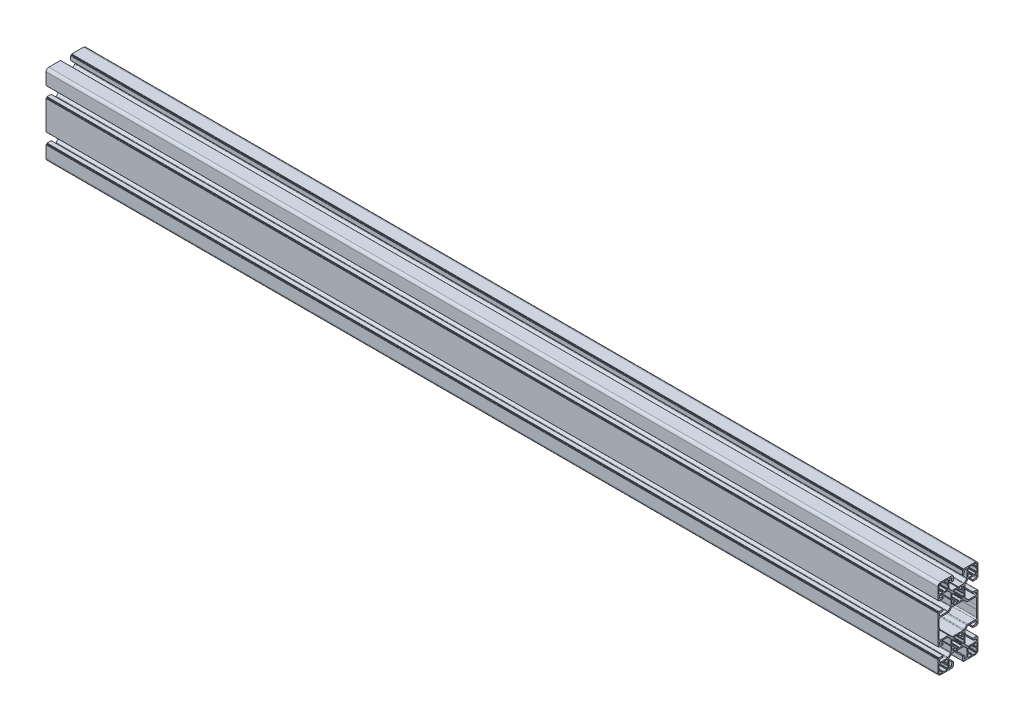
from build123d import *

# Parameters (mm, degrees)
EXTRUDE_1_DEPTH   = 1000
MOVE_BODY_1_ANGLE = 120


with BuildPart() as part:
    # Эскиз1 → Бобышка-Вытянуть1 (new body)
    with BuildSketch(Plane.XY):
        with BuildLine():
            Line((-18.199845697, -23.509977215), (14.150154303, -23.509977215))
            ThreePointArc((14.150154303, -23.509977215), (14.326930998, -23.43675391), (14.400154303, -23.259977215))
            Line((14.400154303, -23.259977215), (14.400154303, -22.609977215))
            ThreePointArc((14.400154303, -22.609977215), (14.429443625, -22.539266537), (14.500154303, -22.509977215))
            Line((14.500154303, -22.509977215), (15.075154303, -22.509977215))
            ThreePointArc((15.075154303, -22.509977215), (15.251930998, -22.43675391), (15.325154303, -22.259977215))
            Line((15.325154303, -22.259977215), (15.325154303, -17.759977215))
            ThreePointArc((15.325154303, -17.759977215), (15.251930998, -17.58320052), (15.075154303, -17.509977215))
            Line((15.075154303, -17.509977215), (13.979405651, -17.509977215))
            ThreePointArc((13.979405651, -17.509977215), (13.821232671, -17.566376314), (13.734426201, -17.710126745))
            Line((13.734426201, -17.710126745), (13.03048423, -21.169498717))
            ThreePointArc((13.03048423, -21.169498717), (12.752703525, -21.629500097), (12.246549992, -21.809977215))
            Line((12.246549992, -21.809977215), (11.175154303, -21.809977215))
            ThreePointArc((11.175154303, -21.809977215), (10.609468878, -21.57566264), (10.375154303, -21.009977215))
            Line((10.375154303, -21.009977215), (10.375154303, -12.726272305))
            ThreePointArc((10.375154303, -12.726272305), (10.451274771, -12.343588873), (10.668047522, -12.019165524))
            Line((10.668047522, -12.019165524), (13.384342612, -9.302870434))
            ThreePointArc((13.384342612, -9.302870434), (13.708765961, -9.086097682), (14.091449394, -9.009977215))
            Line((14.091449394, -9.009977215), (19.944697958, -9.009977215))
            ThreePointArc((19.944697958, -9.009977215), (20.021285838, -8.997956829), (20.090508791, -8.963051588))
            Line((20.090508791, -8.963051588), (20.41682997, -8.728747466))
            ThreePointArc((20.41682997, -8.728747466), (20.475154303, -8.709977215), (20.533478636, -8.728747466))
            Line((20.533478636, -8.728747466), (20.859799816, -8.963051588))
            ThreePointArc((20.859799816, -8.963051588), (20.929022769, -8.997956829), (21.005610648, -9.009977215))
            Line((21.005610648, -9.009977215), (26.858859213, -9.009977215))
            ThreePointArc((26.858859213, -9.009977215), (27.241542645, -9.086097682), (27.565965994, -9.302870434))
            Line((27.565965994, -9.302870434), (30.282261084, -12.019165524))
            ThreePointArc((30.282261084, -12.019165524), (30.499033836, -12.343588873), (30.575154303, -12.726272305))
            Line((30.575154303, -12.726272305), (30.575154303, -21.009977215))
            ThreePointArc((30.575154303, -21.009977215), (30.340839728, -21.57566264), (29.775154303, -21.809977215))
            Line((29.775154303, -21.809977215), (28.703758615, -21.809977215))
            ThreePointArc((28.703758615, -21.809977215), (28.197605082, -21.629500097), (27.919824376, -21.169498717))
            Line((27.919824376, -21.169498717), (27.215882405, -17.710126746))
            ThreePointArc((27.215882405, -17.710126746), (27.129075935, -17.566376315), (26.970902956, -17.509977215))
            Line((26.970902956, -17.509977215), (25.875154303, -17.509977215))
            ThreePointArc((25.875154303, -17.509977215), (25.698377608, -17.58320052), (25.625154303, -17.759977215))
            Line((25.625154303, -17.759977215), (25.625154303, -22.259977215))
            ThreePointArc((25.625154303, -22.259977215), (25.698377608, -22.43675391), (25.875154303, -22.509977215))
            Line((25.875154303, -22.509977215), (26.450154303, -22.509977215))
            ThreePointArc((26.450154303, -22.509977215), (26.520864981, -22.539266537), (26.550154303, -22.609977215))
            Line((26.550154303, -22.609977215), (26.550154303, -23.259977215))
            ThreePointArc((26.550154303, -23.259977215), (26.623377608, -23.43675391), (26.800154303, -23.509977215))
            Line((26.800154303, -23.509977215), (39.975154303, -23.509977215))
            ThreePointArc((39.975154303, -23.509977215), (42.096474645, -22.631297574), (42.975154303, -20.509977239))
            Line((42.975154303, -20.509977239), (42.975154303, -7.334977239))
            ThreePointArc((42.975154303, -7.334977239), (42.901930998, -7.158200544), (42.725154303, -7.084977239))
            Line((42.725154303, -7.084977239), (42.075154303, -7.084977239))
            ThreePointArc((42.075154303, -7.084977239), (42.004443625, -7.055687917), (41.975154303, -6.984977239))
            Line((41.975154303, -6.984977239), (41.975154303, -6.409977239))
            ThreePointArc((41.975154303, -6.409977239), (41.901930998, -6.233200544), (41.725154303, -6.159977239))
            Line((41.725154303, -6.159977239), (37.225154303, -6.159977239))
            ThreePointArc((37.225154303, -6.159977239), (37.048377608, -6.233200544), (36.975154303, -6.409977239))
            Line((36.975154303, -6.409977239), (36.975154303, -7.505725892))
            ThreePointArc((36.975154303, -7.505725892), (37.031553402, -7.663898871), (37.175303834, -7.750705341))
            Line((37.175303834, -7.750705341), (40.634675805, -8.454647312))
            ThreePointArc((40.634675805, -8.454647312), (41.094677185, -8.732428017), (41.275154303, -9.238581551))
            Line((41.275154303, -9.238581551), (41.275154303, -10.309977239))
            ThreePointArc((41.275154303, -10.309977239), (41.040839728, -10.875662664), (40.475154303, -11.109977239))
            Line((40.475154303, -11.109977239), (32.191449393, -11.109977239))
            ThreePointArc((32.191449393, -11.109977239), (31.808765961, -11.033856771), (31.484342612, -10.81708402))
            Line((31.484342612, -10.81708402), (28.768047522, -8.10078893))
            ThreePointArc((28.768047522, -8.10078893), (28.55127477, -7.776365581), (28.475154303, -7.393682149))
            Line((28.475154303, -7.393682149), (28.475154303, -1.540433584))
            ThreePointArc((28.475154303, -1.540433584), (28.463133917, -1.463845704), (28.428228676, -1.394622751))
            Line((28.428228676, -1.394622751), (28.193924554, -1.068301572))
            ThreePointArc((28.193924554, -1.068301572), (28.175154303, -1.009977239), (28.193924554, -0.951652906))
            Line((28.193924554, -0.951652906), (28.428228676, -0.625331726))
            ThreePointArc((28.428228676, -0.625331726), (28.463133917, -0.556108773), (28.475154303, -0.479520894))
            Line((28.475154303, -0.479520894), (28.475154303, 5.373727671))
            ThreePointArc((28.475154303, 5.373727671), (28.55127477, 5.756411103), (28.768047522, 6.080834452))
            Line((28.768047522, 6.080834452), (31.484342612, 8.797129542))
            ThreePointArc((31.484342612, 8.797129542), (31.808765961, 9.013902294), (32.191449393, 9.090022761))
            Line((32.191449393, 9.090022761), (40.475154303, 9.090022761))
            ThreePointArc((40.475154303, 9.090022761), (41.040839728, 8.855708186), (41.275154303, 8.290022761))
            Line((41.275154303, 8.290022761), (41.275154303, 7.218627073))
            ThreePointArc((41.275154303, 7.218627073), (41.094677185, 6.71247354), (40.634675805, 6.434692834))
            Line((40.634675805, 6.434692834), (37.175303834, 5.730750863))
            ThreePointArc((37.175303834, 5.730750863), (37.031553402, 5.643944393), (36.975154303, 5.485771414))
            Line((36.975154303, 5.485771414), (36.975154303, 4.390022761))
            ThreePointArc((36.975154303, 4.390022761), (37.048377608, 4.213246066), (37.225154303, 4.140022761))
            Line((37.225154303, 4.140022761), (41.725154303, 4.140022761))
            ThreePointArc((41.725154303, 4.140022761), (41.901930998, 4.213246066), (41.975154303, 4.390022761))
            Line((41.975154303, 4.390022761), (41.975154303, 4.965022761))
            ThreePointArc((41.975154303, 4.965022761), (42.004443625, 5.035733439), (42.075154303, 5.065022761))
            Line((42.075154303, 5.065022761), (42.725154303, 5.065022761))
            ThreePointArc((42.725154303, 5.065022761), (42.901930998, 5.138246066), (42.975154303, 5.315022761))
            Line((42.975154303, 5.315022761), (42.975154303, 18.490022809))
            ThreePointArc((42.975154303, 18.490022809), (42.096474637, 20.611343152), (39.975154279, 21.490022785))
            Line((39.975154279, 21.490022785), (26.800154279, 21.490022785))
            ThreePointArc((26.800154279, 21.490022785), (26.623377584, 21.41679948), (26.550154279, 21.240022785))
            Line((26.550154279, 21.240022785), (26.550154279, 20.590022785))
            ThreePointArc((26.550154279, 20.590022785), (26.520864957, 20.519312107), (26.450154279, 20.490022785))
            Line((26.450154279, 20.490022785), (25.875154279, 20.490022785))
            ThreePointArc((25.875154279, 20.490022785), (25.698377584, 20.41679948), (25.625154279, 20.240022785))
            Line((25.625154279, 20.240022785), (25.625154279, 15.740022785))
            ThreePointArc((25.625154279, 15.740022785), (25.698377584, 15.56324609), (25.875154279, 15.490022785))
            Line((25.875154279, 15.490022785), (26.970902932, 15.490022785))
            ThreePointArc((26.970902932, 15.490022785), (27.129075911, 15.546421884), (27.215882381, 15.690172316))
            Line((27.215882381, 15.690172316), (27.919824352, 19.149544287))
            ThreePointArc((27.919824352, 19.149544287), (28.197605058, 19.609545667), (28.703758591, 19.790022785))
            Line((28.703758591, 19.790022785), (29.775154279, 19.790022785))
            ThreePointArc((29.775154279, 19.790022785), (30.340839704, 19.55570821), (30.575154279, 18.990022785))
            Line((30.575154279, 18.990022785), (30.575154279, 10.706317875))
            ThreePointArc((30.575154279, 10.706317875), (30.499033812, 10.323634443), (30.28226106, 9.999211094))
            Line((30.28226106, 9.999211094), (27.56596597, 7.282916004))
            ThreePointArc((27.56596597, 7.282916004), (27.241542621, 7.066143252), (26.858859189, 6.990022785))
            Line((26.858859189, 6.990022785), (21.005610624, 6.990022785))
            ThreePointArc((21.005610624, 6.990022785), (20.929022745, 6.978002399), (20.859799792, 6.943097158))
            Line((20.859799792, 6.943097158), (20.533478612, 6.708793036))
            ThreePointArc((20.533478612, 6.708793036), (20.475154279, 6.690022785), (20.416829946, 6.708793036))
            Line((20.416829946, 6.708793036), (20.090508767, 6.943097158))
            ThreePointArc((20.090508767, 6.943097158), (20.021285814, 6.978002399), (19.944697934, 6.990022785))
            Line((19.944697934, 6.990022785), (14.09144937, 6.990022785))
            ThreePointArc((14.09144937, 6.990022785), (13.708765937, 7.066143252), (13.384342588, 7.282916004))
            Line((13.384342588, 7.282916004), (10.668047498, 9.999211094))
            ThreePointArc((10.668047498, 9.999211094), (10.451274747, 10.323634443), (10.375154279, 10.706317875))
            Line((10.375154279, 10.706317875), (10.375154279, 18.990022785))
            ThreePointArc((10.375154279, 18.990022785), (10.609468854, 19.55570821), (11.175154279, 19.790022785))
            Line((11.175154279, 19.790022785), (12.246549968, 19.790022785))
            ThreePointArc((12.246549968, 19.790022785), (12.752703501, 19.609545666), (13.030484206, 19.149544287))
            Line((13.030484206, 19.149544287), (13.734426177, 15.690172315))
            ThreePointArc((13.734426177, 15.690172315), (13.821232647, 15.546421884), (13.979405627, 15.490022785))
            Line((13.979405627, 15.490022785), (15.075154279, 15.490022785))
            ThreePointArc((15.075154279, 15.490022785), (15.251930974, 15.56324609), (15.325154279, 15.740022785))
            Line((15.325154279, 15.740022785), (15.325154279, 20.240022785))
            ThreePointArc((15.325154279, 20.240022785), (15.251930974, 20.41679948), (15.075154279, 20.490022785))
            Line((15.075154279, 20.490022785), (14.500154279, 20.490022785))
            ThreePointArc((14.500154279, 20.490022785), (14.429443601, 20.519312107), (14.400154279, 20.590022785))
            Line((14.400154279, 20.590022785), (14.400154279, 21.240022785))
            ThreePointArc((14.400154279, 21.240022785), (14.326930975, 21.41679948), (14.150154279, 21.490022785))
            Line((14.150154279, 21.490022785), (-18.199845721, 21.490022785))
            ThreePointArc((-18.199845721, 21.490022785), (-18.376622416, 21.41679948), (-18.449845721, 21.240022785))
            Line((-18.449845721, 21.240022785), (-18.449845721, 20.590022785))
            ThreePointArc((-18.449845721, 20.590022785), (-18.479135043, 20.519312107), (-18.549845721, 20.490022785))
            Line((-18.549845721, 20.490022785), (-19.124845721, 20.490022785))
            ThreePointArc((-19.124845721, 20.490022785), (-19.301622416, 20.41679948), (-19.374845721, 20.240022785))
            Line((-19.374845721, 20.240022785), (-19.374845721, 15.740022785))
            ThreePointArc((-19.374845721, 15.740022785), (-19.301622416, 15.56324609), (-19.124845721, 15.490022785))
            Line((-19.124845721, 15.490022785), (-18.029097068, 15.490022785))
            ThreePointArc((-18.029097068, 15.490022785), (-17.870924089, 15.546421884), (-17.784117619, 15.690172315))
            Line((-17.784117619, 15.690172315), (-17.080175648, 19.149544287))
            ThreePointArc((-17.080175648, 19.149544287), (-16.802394942, 19.609545666), (-16.296241409, 19.790022785))
            Line((-16.296241409, 19.790022785), (-15.224845721, 19.790022785))
            ThreePointArc((-15.224845721, 19.790022785), (-14.659160296, 19.55570821), (-14.424845721, 18.990022785))
            Line((-14.424845721, 18.990022785), (-14.424845721, 10.706317875))
            ThreePointArc((-14.424845721, 10.706317875), (-14.500966188, 10.323634443), (-14.71773894, 9.999211094))
            Line((-14.71773894, 9.999211094), (-17.43403403, 7.282916004))
            ThreePointArc((-17.43403403, 7.282916004), (-17.758457379, 7.066143252), (-18.141140811, 6.990022785))
            Line((-18.141140811, 6.990022785), (-23.994389376, 6.990022785))
            ThreePointArc((-23.994389376, 6.990022785), (-24.070977255, 6.978002399), (-24.140200208, 6.943097158))
            Line((-24.140200208, 6.943097158), (-24.466521388, 6.708793036))
            ThreePointArc((-24.466521388, 6.708793036), (-24.524845721, 6.690022785), (-24.583170054, 6.708793036))
            Line((-24.583170054, 6.708793036), (-24.909491233, 6.943097158))
            ThreePointArc((-24.909491233, 6.943097158), (-24.978714186, 6.978002399), (-25.055302066, 6.990022785))
            Line((-25.055302066, 6.990022785), (-30.90855063, 6.990022785))
            ThreePointArc((-30.90855063, 6.990022785), (-31.291234063, 7.066143252), (-31.615657411, 7.282916004))
            Line((-31.615657411, 7.282916004), (-34.331952502, 9.999211094))
            ThreePointArc((-34.331952502, 9.999211094), (-34.548725253, 10.323634443), (-34.624845721, 10.706317875))
            Line((-34.624845721, 10.706317875), (-34.624845721, 18.990022785))
            ThreePointArc((-34.624845721, 18.990022785), (-34.390531146, 19.55570821), (-33.824845721, 19.790022785))
            Line((-33.824845721, 19.790022785), (-32.753450032, 19.790022785))
            ThreePointArc((-32.753450032, 19.790022785), (-32.247296499, 19.609545667), (-31.969515794, 19.149544287))
            Line((-31.969515794, 19.149544287), (-31.265573823, 15.690172316))
            ThreePointArc((-31.265573823, 15.690172316), (-31.178767352, 15.546421884), (-31.020594373, 15.490022785))
            Line((-31.020594373, 15.490022785), (-29.924845721, 15.490022785))
            ThreePointArc((-29.924845721, 15.490022785), (-29.748069025, 15.56324609), (-29.674845721, 15.740022785))
            Line((-29.674845721, 15.740022785), (-29.674845721, 20.240022785))
            ThreePointArc((-29.674845721, 20.240022785), (-29.748069025, 20.41679948), (-29.924845721, 20.490022785))
            Line((-29.924845721, 20.490022785), (-30.499845721, 20.490022785))
            ThreePointArc((-30.499845721, 20.490022785), (-30.570556399, 20.519312107), (-30.599845721, 20.590022785))
            Line((-30.599845721, 20.590022785), (-30.599845721, 21.240022785))
            ThreePointArc((-30.599845721, 21.240022785), (-30.673069025, 21.41679948), (-30.849845721, 21.490022785))
            Line((-30.849845721, 21.490022785), (-44.024845721, 21.490022785))
            ThreePointArc((-44.024845721, 21.490022785), (-46.146166064, 20.611343128), (-47.024845721, 18.490022785))
            Line((-47.024845721, 18.490022785), (-47.024845721, 5.315022785))
            ThreePointArc((-47.024845721, 5.315022785), (-46.951622416, 5.13824609), (-46.774845721, 5.065022785))
            Line((-46.774845721, 5.065022785), (-46.124845721, 5.065022785))
            ThreePointArc((-46.124845721, 5.065022785), (-46.054135043, 5.035733463), (-46.024845721, 4.965022785))
            Line((-46.024845721, 4.965022785), (-46.024845721, 4.390022785))
            ThreePointArc((-46.024845721, 4.390022785), (-45.951622416, 4.21324609), (-45.774845721, 4.140022785))
            Line((-45.774845721, 4.140022785), (-41.274845721, 4.140022785))
            ThreePointArc((-41.274845721, 4.140022785), (-41.098069025, 4.21324609), (-41.024845721, 4.390022785))
            Line((-41.024845721, 4.390022785), (-41.024845721, 5.485771438))
            ThreePointArc((-41.024845721, 5.485771438), (-41.08124482, 5.643944417), (-41.224995251, 5.730750887))
            Line((-41.224995251, 5.730750887), (-44.684367223, 6.434692858))
            ThreePointArc((-44.684367223, 6.434692858), (-45.144368602, 6.712473563), (-45.324845721, 7.218627097))
            Line((-45.324845721, 7.218627097), (-45.324845721, 8.290022785))
            ThreePointArc((-45.324845721, 8.290022785), (-45.090531146, 8.85570821), (-44.524845721, 9.090022785))
            Line((-44.524845721, 9.090022785), (-36.241140811, 9.090022785))
            ThreePointArc((-36.241140811, 9.090022785), (-35.858457379, 9.013902317), (-35.53403403, 8.797129566))
            Line((-35.53403403, 8.797129566), (-32.817738939, 6.080834476))
            ThreePointArc((-32.817738939, 6.080834476), (-32.600966188, 5.756411127), (-32.524845721, 5.373727695))
            Line((-32.524845721, 5.373727695), (-32.524845721, -0.47952087))
            ThreePointArc((-32.524845721, -0.47952087), (-32.512825317, -0.556108771), (-32.477920046, -0.625331736))
            Line((-32.477920046, -0.625331736), (-32.243615947, -0.951652882))
            ThreePointArc((-32.243615947, -0.951652882), (-32.224845697, -1.009977215), (-32.243615947, -1.068301548))
            Line((-32.243615947, -1.068301548), (-32.47792007, -1.394622728))
            ThreePointArc((-32.47792007, -1.394622728), (-32.512825311, -1.46384568), (-32.524845697, -1.54043356))
            Line((-32.524845697, -1.54043356), (-32.524845697, -7.393682125))
            ThreePointArc((-32.524845697, -7.393682125), (-32.600966164, -7.776365557), (-32.817738916, -8.100788906))
            Line((-32.817738916, -8.100788906), (-35.534034006, -10.817083996))
            ThreePointArc((-35.534034006, -10.817083996), (-35.858457355, -11.033856748), (-36.241140787, -11.109977215))
            Line((-36.241140787, -11.109977215), (-44.524845697, -11.109977215))
            ThreePointArc((-44.524845697, -11.109977215), (-45.090531122, -10.87566264), (-45.324845697, -10.309977215))
            Line((-45.324845697, -10.309977215), (-45.324845697, -9.238581527))
            ThreePointArc((-45.324845697, -9.238581527), (-45.144368578, -8.732427994), (-44.684367199, -8.454647288))
            Line((-44.684367199, -8.454647288), (-41.224995227, -7.750705317))
            ThreePointArc((-41.224995227, -7.750705317), (-41.081244796, -7.663898847), (-41.024845697, -7.505725868))
            Line((-41.024845697, -7.505725868), (-41.024845697, -6.409977215))
            ThreePointArc((-41.024845697, -6.409977215), (-41.098069001, -6.23320052), (-41.274845697, -6.159977215))
            Line((-41.274845697, -6.159977215), (-45.774845697, -6.159977215))
            ThreePointArc((-45.774845697, -6.159977215), (-45.951622392, -6.23320052), (-46.024845697, -6.409977215))
            Line((-46.024845697, -6.409977215), (-46.024845697, -6.984977215))
            ThreePointArc((-46.024845697, -6.984977215), (-46.054135018, -7.055687893), (-46.124845697, -7.084977215))
            Line((-46.124845697, -7.084977215), (-46.774845697, -7.084977215))
            ThreePointArc((-46.774845697, -7.084977215), (-46.951622392, -7.15820052), (-47.024845697, -7.334977215))
            Line((-47.024845697, -7.334977215), (-47.024845697, -20.509977215))
            ThreePointArc((-47.024845697, -20.509977215), (-46.14616604, -22.631297559), (-44.024845697, -23.509977215))
            Line((-44.024845697, -23.509977215), (-30.849845697, -23.509977215))
            ThreePointArc((-30.849845697, -23.509977215), (-30.673069001, -23.43675391), (-30.599845697, -23.259977215))
            Line((-30.599845697, -23.259977215), (-30.599845697, -22.609977215))
            ThreePointArc((-30.599845697, -22.609977215), (-30.570556375, -22.539266537), (-30.499845697, -22.509977215))
            Line((-30.499845697, -22.509977215), (-29.924845697, -22.509977215))
            ThreePointArc((-29.924845697, -22.509977215), (-29.748069001, -22.43675391), (-29.674845697, -22.259977215))
            Line((-29.674845697, -22.259977215), (-29.674845697, -17.759977215))
            ThreePointArc((-29.674845697, -17.759977215), (-29.748069001, -17.58320052), (-29.924845697, -17.509977215))
            Line((-29.924845697, -17.509977215), (-31.020594349, -17.509977215))
            ThreePointArc((-31.020594349, -17.509977215), (-31.178767328, -17.566376315), (-31.265573799, -17.710126746))
            Line((-31.265573799, -17.710126746), (-31.96951577, -21.169498717))
            ThreePointArc((-31.96951577, -21.169498717), (-32.247296475, -21.629500097), (-32.753450008, -21.809977215))
            Line((-32.753450008, -21.809977215), (-33.824845697, -21.809977215))
            ThreePointArc((-33.824845697, -21.809977215), (-34.390531122, -21.57566264), (-34.624845697, -21.009977215))
            Line((-34.624845697, -21.009977215), (-34.624845697, -12.726272305))
            ThreePointArc((-34.624845697, -12.726272305), (-34.548725229, -12.343588873), (-34.331952478, -12.019165524))
            Line((-34.331952478, -12.019165524), (-31.615657387, -9.302870434))
            ThreePointArc((-31.615657387, -9.302870434), (-31.291234039, -9.086097683), (-30.908550606, -9.009977215))
            Line((-30.908550606, -9.009977215), (-25.055302042, -9.009977215))
            ThreePointArc((-25.055302042, -9.009977215), (-24.978714162, -8.997956829), (-24.909491209, -8.963051588))
            Line((-24.909491209, -8.963051588), (-24.58317003, -8.728747466))
            ThreePointArc((-24.58317003, -8.728747466), (-24.524845697, -8.709977215), (-24.466521364, -8.728747466))
            Line((-24.466521364, -8.728747466), (-24.140200184, -8.963051588))
            ThreePointArc((-24.140200184, -8.963051588), (-24.070977231, -8.997956829), (-23.994389352, -9.009977215))
            Line((-23.994389352, -9.009977215), (-18.141140787, -9.009977215))
            ThreePointArc((-18.141140787, -9.009977215), (-17.758457355, -9.086097683), (-17.434034006, -9.302870434))
            Line((-17.434034006, -9.302870434), (-14.717738916, -12.019165524))
            ThreePointArc((-14.717738916, -12.019165524), (-14.500966164, -12.343588873), (-14.424845697, -12.726272305))
            Line((-14.424845697, -12.726272305), (-14.424845697, -21.009977215))
            ThreePointArc((-14.424845697, -21.009977215), (-14.659160272, -21.57566264), (-15.224845697, -21.809977215))
            Line((-15.224845697, -21.809977215), (-16.296241385, -21.809977215))
            ThreePointArc((-16.296241385, -21.809977215), (-16.802394918, -21.629500097), (-17.080175624, -21.169498717))
            Line((-17.080175624, -21.169498717), (-17.784117594, -17.710126746))
            ThreePointArc((-17.784117594, -17.710126746), (-17.870924065, -17.566376314), (-18.029097044, -17.509977215))
            Line((-18.029097044, -17.509977215), (-19.124845697, -17.509977215))
            ThreePointArc((-19.124845697, -17.509977215), (-19.301622392, -17.58320052), (-19.374845697, -17.759977215))
            Line((-19.374845697, -17.759977215), (-19.374845697, -22.259977215))
            ThreePointArc((-19.374845697, -22.259977215), (-19.301622392, -22.43675391), (-19.124845697, -22.509977215))
            Line((-19.124845697, -22.509977215), (-18.549845697, -22.509977215))
            ThreePointArc((-18.549845697, -22.509977215), (-18.479135019, -22.539266537), (-18.449845697, -22.609977215))
            Line((-18.449845697, -22.609977215), (-18.449845697, -23.259977215))
            ThreePointArc((-18.449845697, -23.259977215), (-18.376622392, -23.43675391), (-18.199845697, -23.509977215))
        make_face()
        with BuildLine():
            Line((-35.824845673, 14.578241013), (-35.824845673, 11.290022785))
            ThreePointArc((-35.824845673, 11.290022785), (-35.829980955, 11.188809182), (-35.84533406, 11.0886351))
            ThreePointArc((-35.84533406, 11.0886351), (-35.932235272, 10.945220918), (-36.090211963, 10.888982021))
            Line((-36.090211963, 10.888982021), (-36.223804909, 10.888982021))
            ThreePointArc((-36.223804909, 10.888982021), (-36.365226265, 10.830403377), (-36.423804909, 10.688982021))
            Line((-36.423804909, 10.688982021), (-36.423804909, 10.555389075))
            ThreePointArc((-36.423804909, 10.555389075), (-36.480043806, 10.397412384), (-36.623457988, 10.310511172))
            ThreePointArc((-36.623457988, 10.310511172), (-36.72363207, 10.295158067), (-36.824845673, 10.290022785))
            Line((-36.824845673, 10.290022785), (-40.113063901, 10.290022785))
            ThreePointArc((-40.113063901, 10.290022785), (-40.274657625, 10.349267789), (-40.359662382, 10.498923038))
            Line((-40.359662382, 10.498923038), (-40.490028964, 11.281122532))
            ThreePointArc((-40.490028964, 11.281122532), (-40.575033721, 11.430777781), (-40.736627445, 11.490022785))
            Line((-40.736627445, 11.490022785), (-41.313063901, 11.490022785))
            ThreePointArc((-41.313063901, 11.490022785), (-41.474657625, 11.430777781), (-41.559662382, 11.281122532))
            Line((-41.559662382, 11.281122532), (-41.690028964, 10.498923038))
            ThreePointArc((-41.690028964, 10.498923038), (-41.775033721, 10.349267789), (-41.936627445, 10.290022785))
            Line((-41.936627445, 10.290022785), (-44.824845673, 10.290022785))
            ThreePointArc((-44.824845673, 10.290022785), (-44.926059276, 10.295158067), (-45.026233358, 10.310511172))
            ThreePointArc((-45.026233358, 10.310511172), (-45.16964754, 10.397412384), (-45.225886437, 10.555389075))
            Line((-45.225886437, 10.555389075), (-45.225886437, 10.688982021))
            ThreePointArc((-45.225886437, 10.688982021), (-45.284465081, 10.830403377), (-45.425886437, 10.888982021))
            Line((-45.425886437, 10.888982021), (-45.559479383, 10.888982021))
            ThreePointArc((-45.559479383, 10.888982021), (-45.717456074, 10.945220918), (-45.804357286, 11.0886351))
            ThreePointArc((-45.804357286, 11.0886351), (-45.819710391, 11.188809182), (-45.824845673, 11.290022785))
            Line((-45.824845673, 11.290022785), (-45.824845673, 14.594828683))
            ThreePointArc((-45.824845673, 14.594828683), (-45.771897032, 14.748681736), (-45.635479579, 14.837364308))
            Line((-45.635479579, 14.837364308), (-45.214211767, 14.942681261))
            ThreePointArc((-45.214211767, 14.942681261), (-45.077794313, 15.031363834), (-45.024845673, 15.185216886))
            Line((-45.024845673, 15.185216886), (-45.024845673, 15.794828683))
            ThreePointArc((-45.024845673, 15.794828683), (-45.077794314, 15.948681736), (-45.214211767, 16.037364308))
            Line((-45.214211767, 16.037364308), (-45.635479579, 16.142681261))
            ThreePointArc((-45.635479579, 16.142681261), (-45.771897034, 16.231363836), (-45.824845673, 16.385216892))
            Line((-45.824845673, 16.385216892), (-45.824845673, 18.490022785))
            ThreePointArc((-45.824845673, 18.490022785), (-45.773103197, 18.918503387), (-45.620850527, 19.322349937))
            ThreePointArc((-45.620850527, 19.322349937), (-45.52879752, 19.420524815), (-45.399183187, 19.45674894))
            Line((-45.399183187, 19.45674894), (-45.191571876, 19.45674894))
            ThreePointArc((-45.191571876, 19.45674894), (-45.05015052, 19.515327584), (-44.991571876, 19.65674894))
            Line((-44.991571876, 19.65674894), (-44.991571876, 19.864360251))
            ThreePointArc((-44.991571876, 19.864360251), (-44.955347751, 19.993974585), (-44.857172872, 20.086027591))
            ThreePointArc((-44.857172872, 20.086027591), (-44.453326323, 20.238280261), (-44.024845721, 20.290022737))
            Line((-44.024845721, 20.290022737), (-41.920039822, 20.290022737))
            ThreePointArc((-41.920039822, 20.290022737), (-41.76618677, 20.237074097), (-41.677504197, 20.100656643))
            Line((-41.677504197, 20.100656643), (-41.572187244, 19.679388831))
            ThreePointArc((-41.572187244, 19.679388831), (-41.483504672, 19.542971378), (-41.329651619, 19.490022737))
            Line((-41.329651619, 19.490022737), (-40.720039822, 19.490022737))
            ThreePointArc((-40.720039822, 19.490022737), (-40.56618677, 19.542971378), (-40.477504197, 19.679388831))
            Line((-40.477504197, 19.679388831), (-40.372187244, 20.100656643))
            ThreePointArc((-40.372187244, 20.100656643), (-40.283504671, 20.237074097), (-40.129651619, 20.290022737))
            Line((-40.129651619, 20.290022737), (-36.824845721, 20.290022737))
            ThreePointArc((-36.824845721, 20.290022737), (-36.723632118, 20.284887455), (-36.623458035, 20.26953435))
            ThreePointArc((-36.623458035, 20.26953435), (-36.480043853, 20.182633138), (-36.423804957, 20.024656447))
            Line((-36.423804957, 20.024656447), (-36.423804957, 19.891063501))
            ThreePointArc((-36.423804957, 19.891063501), (-36.365226313, 19.749642145), (-36.223804957, 19.691063501))
            Line((-36.223804957, 19.691063501), (-36.090212011, 19.691063501))
            ThreePointArc((-36.090212011, 19.691063501), (-35.93223532, 19.634824605), (-35.845334108, 19.491410423))
            ThreePointArc((-35.845334108, 19.491410423), (-35.829981003, 19.39123634), (-35.824845721, 19.290022737))
            Line((-35.824845721, 19.290022737), (-35.824845721, 16.401804509))
            ThreePointArc((-35.824845721, 16.401804509), (-35.884090722, 16.240210828), (-36.033745926, 16.155206076))
            Line((-36.033745926, 16.155206076), (-36.81594542, 16.024839494))
            ThreePointArc((-36.81594542, 16.024839494), (-36.965600668, 15.939834737), (-37.024845673, 15.778241013))
            Line((-37.024845673, 15.778241013), (-37.024845673, 15.201804557))
            ThreePointArc((-37.024845673, 15.201804557), (-36.965600669, 15.040210833), (-36.81594542, 14.955206076))
            Line((-36.81594542, 14.955206076), (-36.033745926, 14.824839494))
            ThreePointArc((-36.033745926, 14.824839494), (-35.884090677, 14.739834737), (-35.824845673, 14.578241013))
        make_face(mode=Mode.SUBTRACT)
        with BuildLine():
            Line((-40.113063901, -12.309977215), (-36.824845673, -12.309977215))
            ThreePointArc((-36.824845673, -12.309977215), (-36.72363207, -12.315112497), (-36.623457988, -12.330465602))
            ThreePointArc((-36.623457988, -12.330465602), (-36.480043806, -12.417366814), (-36.423804909, -12.575343505))
            Line((-36.423804909, -12.575343505), (-36.423804909, -12.708936451))
            ThreePointArc((-36.423804909, -12.708936451), (-36.365226265, -12.850357807), (-36.223804909, -12.908936451))
            Line((-36.223804909, -12.908936451), (-36.090211963, -12.908936451))
            ThreePointArc((-36.090211963, -12.908936451), (-35.932235272, -12.965175348), (-35.84533406, -13.10858953))
            ThreePointArc((-35.84533406, -13.10858953), (-35.829980955, -13.208763612), (-35.824845673, -13.309977215))
            Line((-35.824845673, -13.309977215), (-35.824845673, -16.598195443))
            ThreePointArc((-35.824845673, -16.598195443), (-35.884090688, -16.759789147), (-36.033745926, -16.844793892))
            Line((-36.033745926, -16.844793892), (-36.815945443, -16.975160478))
            ThreePointArc((-36.815945443, -16.975160478), (-36.965600692, -17.060165235), (-37.024845697, -17.221758959))
            Line((-37.024845697, -17.221758959), (-37.024845697, -17.798195415))
            ThreePointArc((-37.024845697, -17.798195415), (-36.965600692, -17.959789139), (-36.815945443, -18.044793896))
            Line((-36.815945443, -18.044793896), (-36.03374595, -18.175160478))
            ThreePointArc((-36.03374595, -18.175160478), (-35.884090701, -18.260165235), (-35.824845697, -18.421758959))
            Line((-35.824845697, -18.421758959), (-35.824845697, -21.309977187))
            ThreePointArc((-35.824845697, -21.309977187), (-35.829980979, -21.41119079), (-35.845334084, -21.511364872))
            ThreePointArc((-35.845334084, -21.511364872), (-35.932235296, -21.654779054), (-36.090211987, -21.711017951))
            Line((-36.090211987, -21.711017951), (-36.223804933, -21.711017951))
            ThreePointArc((-36.223804933, -21.711017951), (-36.365226289, -21.769596595), (-36.423804933, -21.911017951))
            Line((-36.423804933, -21.911017951), (-36.423804933, -22.044610897))
            ThreePointArc((-36.423804933, -22.044610897), (-36.480043829, -22.202587588), (-36.623458011, -22.2894888))
            ThreePointArc((-36.623458011, -22.2894888), (-36.723632094, -22.304841905), (-36.824845697, -22.309977187))
            Line((-36.824845697, -22.309977187), (-40.129651595, -22.309977187))
            ThreePointArc((-40.129651595, -22.309977187), (-40.283504647, -22.257028546), (-40.37218722, -22.120611093))
            Line((-40.37218722, -22.120611093), (-40.477504173, -21.699343281))
            ThreePointArc((-40.477504173, -21.699343281), (-40.566186746, -21.562925827), (-40.720039798, -21.509977187))
            Line((-40.720039798, -21.509977187), (-41.329651595, -21.509977187))
            ThreePointArc((-41.329651595, -21.509977187), (-41.483504647, -21.562925827), (-41.57218722, -21.699343281))
            Line((-41.57218722, -21.699343281), (-41.677504173, -22.120611093))
            ThreePointArc((-41.677504173, -22.120611093), (-41.766186748, -22.257028548), (-41.920039804, -22.309977187))
            Line((-41.920039804, -22.309977187), (-44.024845697, -22.309977187))
            ThreePointArc((-44.024845697, -22.309977187), (-44.45332631, -22.258234708), (-44.857172869, -22.105982032))
            ThreePointArc((-44.857172869, -22.105982032), (-44.955347748, -22.013929026), (-44.991571873, -21.884314692))
            Line((-44.991571873, -21.884314692), (-44.991571873, -21.676703381))
            ThreePointArc((-44.991571873, -21.676703381), (-45.050150517, -21.535282025), (-45.191571873, -21.476703381))
            Line((-45.191571873, -21.476703381), (-45.399183184, -21.476703381))
            ThreePointArc((-45.399183184, -21.476703381), (-45.528797517, -21.440479256), (-45.620850524, -21.342304378))
            ThreePointArc((-45.620850524, -21.342304378), (-45.773103196, -20.938457823), (-45.824845673, -20.509977215))
            Line((-45.824845673, -20.509977215), (-45.824845673, -18.405171317))
            ThreePointArc((-45.824845673, -18.405171317), (-45.771897032, -18.251318264), (-45.635479579, -18.162635692))
            Line((-45.635479579, -18.162635692), (-45.214211767, -18.057318739))
            ThreePointArc((-45.214211767, -18.057318739), (-45.077794313, -17.968636166), (-45.024845673, -17.814783114))
            Line((-45.024845673, -17.814783114), (-45.024845673, -17.205171317))
            ThreePointArc((-45.024845673, -17.205171317), (-45.077794313, -17.051318264), (-45.214211767, -16.962635692))
            Line((-45.214211767, -16.962635692), (-45.635479579, -16.857318739))
            ThreePointArc((-45.635479579, -16.857318739), (-45.771897032, -16.768636166), (-45.824845673, -16.614783113))
            Line((-45.824845673, -16.614783113), (-45.824845673, -13.309977215))
            ThreePointArc((-45.824845673, -13.309977215), (-45.819710391, -13.208763612), (-45.804357286, -13.10858953))
            ThreePointArc((-45.804357286, -13.10858953), (-45.717456074, -12.965175348), (-45.559479383, -12.908936451))
            Line((-45.559479383, -12.908936451), (-45.425886437, -12.908936451))
            ThreePointArc((-45.425886437, -12.908936451), (-45.284465081, -12.850357807), (-45.225886437, -12.708936451))
            Line((-45.225886437, -12.708936451), (-45.225886437, -12.575343505))
            ThreePointArc((-45.225886437, -12.575343505), (-45.16964754, -12.417366814), (-45.026233358, -12.330465602))
            ThreePointArc((-45.026233358, -12.330465602), (-44.926059276, -12.315112497), (-44.824845673, -12.309977215))
            Line((-44.824845673, -12.309977215), (-41.936627445, -12.309977215))
            ThreePointArc((-41.936627445, -12.309977215), (-41.775033721, -12.369222219), (-41.690028964, -12.518877468))
            Line((-41.690028964, -12.518877468), (-41.559662382, -13.301076962))
            ThreePointArc((-41.559662382, -13.301076962), (-41.474657625, -13.450732211), (-41.313063901, -13.509977215))
            Line((-41.313063901, -13.509977215), (-40.736627445, -13.509977215))
            ThreePointArc((-40.736627445, -13.509977215), (-40.575033721, -13.450732211), (-40.490028964, -13.301076962))
            Line((-40.490028964, -13.301076962), (-40.359662382, -12.518877468))
            ThreePointArc((-40.359662382, -12.518877468), (-40.274657625, -12.369222219), (-40.113063901, -12.309977215))
        make_face(mode=Mode.SUBTRACT)
        with BuildLine():
            Line((-13.024845673, 18.590022785), (-13.024845673, 9.726418888))
            ThreePointArc((-13.024845673, 9.726418888), (-13.131414327, 9.190662083), (-13.434896179, 8.736469394))
            Line((-13.434896179, 8.736469394), (-16.114795167, 6.056570407))
            ThreePointArc((-16.114795167, 6.056570407), (-16.418277018, 5.602377719), (-16.524845673, 5.066620913))
            Line((-16.524845673, 5.066620913), (-16.524845673, -7.086575343))
            ThreePointArc((-16.524845673, -7.086575343), (-16.418277018, -7.622332149), (-16.114795167, -8.076524837))
            Line((-16.114795167, -8.076524837), (-13.434896179, -10.756423824))
            ThreePointArc((-13.434896179, -10.756423824), (-13.131414327, -11.210616513), (-13.024845673, -11.746373318))
            Line((-13.024845673, -11.746373318), (-13.024845673, -20.609977215))
            ThreePointArc((-13.024845673, -20.609977215), (-12.614795166, -21.599926709), (-11.624845673, -22.009977215))
            Line((-11.624845673, -22.009977215), (-4.049691346, -22.009977215))
            ThreePointArc((-4.049691346, -22.009977215), (-4.025184192, -22.008470035), (-4.001046405, -22.003971209))
            ThreePointArc((-4.001046405, -22.003971209), (-2.024845673, -21.759977215), (-0.048644941, -22.003971209))
            ThreePointArc((-0.048644941, -22.003971209), (-0.024507154, -22.008470035), (0, -22.009977215))
            Line((0, -22.009977215), (7.575154327, -22.009977215))
            ThreePointArc((7.575154327, -22.009977215), (8.565103821, -21.599926709), (8.975154327, -20.609977215))
            Line((8.975154327, -20.609977215), (8.975154327, -11.746373318))
            ThreePointArc((8.975154327, -11.746373318), (9.081722982, -11.210616513), (9.385204833, -10.756423824))
            Line((9.385204833, -10.756423824), (12.065103821, -8.076524837))
            ThreePointArc((12.065103821, -8.076524837), (12.368585673, -7.622332149), (12.475154327, -7.086575344))
            Line((12.475154327, -7.086575344), (12.475154327, 5.066620913))
            ThreePointArc((12.475154327, 5.066620913), (12.368585672, 5.602377719), (12.065103821, 6.056570407))
            Line((12.065103821, 6.056570407), (9.385204833, 8.736469394))
            ThreePointArc((9.385204833, 8.736469394), (9.081722981, 9.190662083), (8.975154327, 9.726418888))
            Line((8.975154327, 9.726418888), (8.975154327, 18.590022785))
            ThreePointArc((8.975154327, 18.590022785), (8.565103821, 19.579972279), (7.575154327, 19.990022785))
            Line((7.575154327, 19.990022785), (0, 19.990022785))
            ThreePointArc((0, 19.990022785), (-0.024507154, 19.988515604), (-0.048644941, 19.984016779))
            ThreePointArc((-0.048644941, 19.984016779), (-2.024845673, 19.740022785), (-4.001046405, 19.984016779))
            ThreePointArc((-4.001046405, 19.984016779), (-4.025184192, 19.988515604), (-4.049691346, 19.990022785))
            Line((-4.049691346, 19.990022785), (-11.624845673, 19.990022785))
            ThreePointArc((-11.624845673, 19.990022785), (-12.614795167, 19.579972279), (-13.024845673, 18.590022785))
        make_face(mode=Mode.SUBTRACT)
        with BuildLine():
            Line((32.775154327, 10.290022785), (36.063372555, 10.290022785))
            ThreePointArc((36.063372555, 10.290022785), (36.224966279, 10.349267789), (36.309971036, 10.498923038))
            Line((36.309971036, 10.498923038), (36.440337618, 11.281122532))
            ThreePointArc((36.440337618, 11.281122532), (36.525342375, 11.430777781), (36.686936099, 11.490022785))
            Line((36.686936099, 11.490022785), (37.263372555, 11.490022785))
            ThreePointArc((37.263372555, 11.490022785), (37.424966279, 11.430777781), (37.509971036, 11.281122532))
            Line((37.509971036, 11.281122532), (37.640337618, 10.498923038))
            ThreePointArc((37.640337618, 10.498923038), (37.725342375, 10.349267789), (37.886936099, 10.290022785))
            Line((37.886936099, 10.290022785), (40.775154327, 10.290022785))
            ThreePointArc((40.775154327, 10.290022785), (40.87636793, 10.295158067), (40.976542012, 10.310511172))
            ThreePointArc((40.976542012, 10.310511172), (41.119956194, 10.397412384), (41.176195091, 10.555389075))
            Line((41.176195091, 10.555389075), (41.176195091, 10.688982021))
            ThreePointArc((41.176195091, 10.688982021), (41.234773735, 10.830403377), (41.376195091, 10.888982021))
            Line((41.376195091, 10.888982021), (41.509788037, 10.888982021))
            ThreePointArc((41.509788037, 10.888982021), (41.667764728, 10.945220918), (41.75466594, 11.0886351))
            ThreePointArc((41.75466594, 11.0886351), (41.770019045, 11.188809182), (41.775154327, 11.290022785))
            Line((41.775154327, 11.290022785), (41.775154327, 14.594828683))
            ThreePointArc((41.775154327, 14.594828683), (41.722205686, 14.748681736), (41.585788233, 14.837364308))
            Line((41.585788233, 14.837364308), (41.164520421, 14.942681261))
            ThreePointArc((41.164520421, 14.942681261), (41.028102967, 15.031363834), (40.975154327, 15.185216886))
            Line((40.975154327, 15.185216886), (40.975154327, 15.794828683))
            ThreePointArc((40.975154327, 15.794828683), (41.028102968, 15.948681736), (41.164520421, 16.037364308))
            Line((41.164520421, 16.037364308), (41.585788233, 16.142681261))
            ThreePointArc((41.585788233, 16.142681261), (41.722205659, 16.231363849), (41.775154279, 16.385216892))
            Line((41.775154279, 16.385216892), (41.775154279, 18.490022809))
            ThreePointArc((41.775154279, 18.490022809), (41.723411803, 18.918503411), (41.571159133, 19.32234996))
            ThreePointArc((41.571159133, 19.32234996), (41.479106126, 19.420524854), (41.349491782, 19.456748985))
            Line((41.349491782, 19.456748985), (41.141880493, 19.456748985))
            ThreePointArc((41.141880493, 19.456748985), (41.000459137, 19.515327629), (40.941880493, 19.656748985))
            Line((40.941880493, 19.656748985), (40.941880493, 19.864360296))
            ThreePointArc((40.941880493, 19.864360296), (40.905656368, 19.993974629), (40.807481489, 20.086027636))
            ThreePointArc((40.807481489, 20.086027636), (40.403634935, 20.238280308), (39.975154327, 20.290022785))
            Line((39.975154327, 20.290022785), (37.870348428, 20.290022785))
            ThreePointArc((37.870348428, 20.290022785), (37.716495376, 20.237074144), (37.627812803, 20.100656691))
            Line((37.627812803, 20.100656691), (37.52249585, 19.679388879))
            ThreePointArc((37.52249585, 19.679388879), (37.433813278, 19.542971425), (37.279960225, 19.490022785))
            Line((37.279960225, 19.490022785), (36.670348428, 19.490022785))
            ThreePointArc((36.670348428, 19.490022785), (36.516495376, 19.542971425), (36.427812803, 19.679388879))
            Line((36.427812803, 19.679388879), (36.32249585, 20.100656691))
            ThreePointArc((36.32249585, 20.100656691), (36.233813278, 20.237074144), (36.079960225, 20.290022785))
            Line((36.079960225, 20.290022785), (32.775154327, 20.290022785))
            ThreePointArc((32.775154327, 20.290022785), (32.673940724, 20.284887503), (32.573766641, 20.269534398))
            ThreePointArc((32.573766641, 20.269534398), (32.430352459, 20.182633186), (32.374113563, 20.024656495))
            Line((32.374113563, 20.024656495), (32.374113563, 19.891063549))
            ThreePointArc((32.374113563, 19.891063549), (32.315534919, 19.749642193), (32.174113563, 19.691063549))
            Line((32.174113563, 19.691063549), (32.040520617, 19.691063549))
            ThreePointArc((32.040520617, 19.691063549), (31.882543926, 19.634824652), (31.795642714, 19.49141047))
            ThreePointArc((31.795642714, 19.49141047), (31.780289609, 19.391236388), (31.775154327, 19.290022785))
            Line((31.775154327, 19.290022785), (31.775154327, 16.401804557))
            ThreePointArc((31.775154327, 16.401804557), (31.834399331, 16.240210833), (31.98405458, 16.155206076))
            Line((31.98405458, 16.155206076), (32.766254074, 16.024839494))
            ThreePointArc((32.766254074, 16.024839494), (32.915909322, 15.939834737), (32.975154327, 15.778241013))
            Line((32.975154327, 15.778241013), (32.975154327, 15.201804557))
            ThreePointArc((32.975154327, 15.201804557), (32.915909323, 15.040210833), (32.766254074, 14.955206076))
            Line((32.766254074, 14.955206076), (31.98405458, 14.824839494))
            ThreePointArc((31.98405458, 14.824839494), (31.834399331, 14.739834737), (31.775154327, 14.578241013))
            Line((31.775154327, 14.578241013), (31.775154327, 11.290022785))
            ThreePointArc((31.775154327, 11.290022785), (31.780289609, 11.188809182), (31.795642714, 11.0886351))
            ThreePointArc((31.795642714, 11.0886351), (31.882543926, 10.945220918), (32.040520617, 10.888982021))
            Line((32.040520617, 10.888982021), (32.174113563, 10.888982021))
            ThreePointArc((32.174113563, 10.888982021), (32.315534919, 10.830403377), (32.374113563, 10.688982021))
            Line((32.374113563, 10.688982021), (32.374113563, 10.555389075))
            ThreePointArc((32.374113563, 10.555389075), (32.43035246, 10.397412384), (32.573766642, 10.310511172))
            ThreePointArc((32.573766642, 10.310511172), (32.673940724, 10.295158067), (32.775154327, 10.290022785))
        make_face(mode=Mode.SUBTRACT)
        with BuildLine():
            Line((32.775154327, -12.309977215), (36.063372555, -12.309977215))
            ThreePointArc((36.063372555, -12.309977215), (36.224966279, -12.369222219), (36.309971036, -12.518877468))
            Line((36.309971036, -12.518877468), (36.440337618, -13.301076962))
            ThreePointArc((36.440337618, -13.301076962), (36.525342375, -13.450732211), (36.686936099, -13.509977215))
            Line((36.686936099, -13.509977215), (37.263372555, -13.509977215))
            ThreePointArc((37.263372555, -13.509977215), (37.424966279, -13.450732211), (37.509971036, -13.301076962))
            Line((37.509971036, -13.301076962), (37.640337618, -12.518877468))
            ThreePointArc((37.640337618, -12.518877468), (37.725342375, -12.369222219), (37.886936099, -12.309977215))
            Line((37.886936099, -12.309977215), (40.775154327, -12.309977215))
            ThreePointArc((40.775154327, -12.309977215), (40.87636793, -12.315112497), (40.976542012, -12.330465602))
            ThreePointArc((40.976542012, -12.330465602), (41.119956194, -12.417366814), (41.176195091, -12.575343505))
            Line((41.176195091, -12.575343505), (41.176195091, -12.708936451))
            ThreePointArc((41.176195091, -12.708936451), (41.234773735, -12.850357807), (41.376195091, -12.908936451))
            Line((41.376195091, -12.908936451), (41.509788037, -12.908936451))
            ThreePointArc((41.509788037, -12.908936451), (41.667764728, -12.965175348), (41.75466594, -13.10858953))
            ThreePointArc((41.75466594, -13.10858953), (41.770019045, -13.208763612), (41.775154327, -13.309977215))
            Line((41.775154327, -13.309977215), (41.775154327, -16.614783113))
            ThreePointArc((41.775154327, -16.614783113), (41.722205675, -16.768636192), (41.585788186, -16.857318762))
            Line((41.585788186, -16.857318762), (41.164520373, -16.962635715))
            ThreePointArc((41.164520373, -16.962635715), (41.02810292, -17.051318288), (40.975154279, -17.20517134))
            Line((40.975154279, -17.20517134), (40.975154279, -17.814783137))
            ThreePointArc((40.975154279, -17.814783137), (41.02810292, -17.96863619), (41.164520373, -18.057318762))
            Line((41.164520373, -18.057318762), (41.585788186, -18.162635715))
            ThreePointArc((41.585788186, -18.162635715), (41.722205641, -18.25131829), (41.775154279, -18.405171346))
            Line((41.775154279, -18.405171346), (41.775154279, -20.509977239))
            ThreePointArc((41.775154279, -20.509977239), (41.723411803, -20.938457841), (41.571159133, -21.34230439))
            ThreePointArc((41.571159133, -21.34230439), (41.479106126, -21.440479284), (41.349491782, -21.476703415))
            Line((41.349491782, -21.476703415), (41.141880493, -21.476703415))
            ThreePointArc((41.141880493, -21.476703415), (41.000459137, -21.535282059), (40.941880493, -21.676703415))
            Line((40.941880493, -21.676703415), (40.941880493, -21.884314726))
            ThreePointArc((40.941880493, -21.884314726), (40.905656368, -22.01392906), (40.80748149, -22.105982066))
            ThreePointArc((40.80748149, -22.105982066), (40.403634935, -22.258234738), (39.975154327, -22.309977215))
            Line((39.975154327, -22.309977215), (37.870348429, -22.309977215))
            ThreePointArc((37.870348429, -22.309977215), (37.716495376, -22.257028575), (37.627812804, -22.120611121))
            Line((37.627812804, -22.120611121), (37.52249585, -21.699343309))
            ThreePointArc((37.52249585, -21.699343309), (37.433813278, -21.562925856), (37.279960225, -21.509977215))
            Line((37.279960225, -21.509977215), (36.670348429, -21.509977215))
            ThreePointArc((36.670348429, -21.509977215), (36.516495376, -21.562925856), (36.427812803, -21.699343309))
            Line((36.427812803, -21.699343309), (36.32249585, -22.120611121))
            ThreePointArc((36.32249585, -22.120611121), (36.233813278, -22.257028575), (36.079960225, -22.309977215))
            Line((36.079960225, -22.309977215), (32.775154327, -22.309977215))
            ThreePointArc((32.775154327, -22.309977215), (32.673940724, -22.304841933), (32.573766642, -22.289488828))
            ThreePointArc((32.573766642, -22.289488828), (32.43035246, -22.202587616), (32.374113563, -22.044610925))
            Line((32.374113563, -22.044610925), (32.374113563, -21.911017979))
            ThreePointArc((32.374113563, -21.911017979), (32.315534919, -21.769596623), (32.174113563, -21.711017979))
            Line((32.174113563, -21.711017979), (32.040520617, -21.711017979))
            ThreePointArc((32.040520617, -21.711017979), (31.882543926, -21.654779082), (31.795642714, -21.5113649))
            ThreePointArc((31.795642714, -21.5113649), (31.780289609, -21.411190818), (31.775154327, -21.309977215))
            Line((31.775154327, -21.309977215), (31.775154327, -18.421758987))
            ThreePointArc((31.775154327, -18.421758987), (31.834399331, -18.260165263), (31.98405458, -18.175160506))
            Line((31.98405458, -18.175160506), (32.766254074, -18.044793924))
            ThreePointArc((32.766254074, -18.044793924), (32.915909323, -17.959789167), (32.975154327, -17.798195443))
            Line((32.975154327, -17.798195443), (32.975154327, -17.221758987))
            ThreePointArc((32.975154327, -17.221758987), (32.915909323, -17.060165263), (32.766254074, -16.975160506))
            Line((32.766254074, -16.975160506), (31.98405458, -16.844793924))
            ThreePointArc((31.98405458, -16.844793924), (31.834399331, -16.759789167), (31.775154327, -16.598195443))
            Line((31.775154327, -16.598195443), (31.775154327, -13.309977215))
            ThreePointArc((31.775154327, -13.309977215), (31.780289609, -13.208763612), (31.795642714, -13.10858953))
            ThreePointArc((31.795642714, -13.10858953), (31.882543926, -12.965175348), (32.040520617, -12.908936451))
            Line((32.040520617, -12.908936451), (32.174113563, -12.908936451))
            ThreePointArc((32.174113563, -12.908936451), (32.315534919, -12.850357807), (32.374113563, -12.708936451))
            Line((32.374113563, -12.708936451), (32.374113563, -12.575343505))
            ThreePointArc((32.374113563, -12.575343505), (32.43035246, -12.417366814), (32.573766642, -12.330465602))
            ThreePointArc((32.573766642, -12.330465602), (32.673940724, -12.315112497), (32.775154327, -12.309977215))
        make_face(mode=Mode.SUBTRACT)
        with BuildLine():
            Line((-29.367096972, -7.749977163), (-25.53482288, -7.749977163))
            ThreePointArc((-25.53482288, -7.749977163), (-25.338353536, -7.676692396), (-25.23787226, -7.492642475))
            Line((-25.23787226, -7.492642475), (-25.055656819, -6.224422789))
            ThreePointArc((-25.055656819, -6.224422789), (-24.971922422, -6.071047854), (-24.808197968, -6.009977215))
            Line((-24.808197968, -6.009977215), (-24.241493378, -6.009977215))
            ThreePointArc((-24.241493378, -6.009977215), (-24.077768924, -6.071047854), (-23.994034527, -6.224422789))
            Line((-23.994034527, -6.224422789), (-23.811819086, -7.492642475))
            ThreePointArc((-23.811819086, -7.492642475), (-23.71133781, -7.676692396), (-23.514868465, -7.749977163))
            Line((-23.514868465, -7.749977163), (-19.682594374, -7.749977163))
            ThreePointArc((-19.682594374, -7.749977163), (-19.412140982, -7.579803828), (-19.448513961, -7.262343582))
            Line((-19.448513961, -7.262343582), (-21.202779704, -5.073826756))
            ThreePointArc((-21.202779704, -5.073826756), (-21.25733675, -4.9037603), (-21.184489389, -4.740688743))
            Line((-21.184489389, -4.740688743), (-20.794134145, -4.350333499))
            ThreePointArc((-20.794134145, -4.350333499), (-20.631062588, -4.277486138), (-20.460996132, -4.332043184))
            Line((-20.460996132, -4.332043184), (-18.272479254, -6.086308968))
            ThreePointArc((-18.272479254, -6.086308968), (-17.955019008, -6.122681948), (-17.784845673, -5.852228556))
            Line((-17.784845673, -5.852228556), (-17.784845673, -2.01995443))
            ThreePointArc((-17.784845673, -2.01995443), (-17.85813044, -1.823485086), (-18.042180361, -1.723003809))
            Line((-18.042180361, -1.723003809), (-19.310400099, -1.540788361))
            ThreePointArc((-19.310400099, -1.540788361), (-19.463775034, -1.457053964), (-19.524845673, -1.29332951))
            Line((-19.524845673, -1.29332951), (-19.524845673, -0.72662492))
            ThreePointArc((-19.524845673, -0.72662492), (-19.463775034, -0.562900466), (-19.310400099, -0.479166069))
            Line((-19.310400099, -0.479166069), (-18.042180361, -0.296950621))
            ThreePointArc((-18.042180361, -0.296950621), (-17.85813044, -0.196469344), (-17.784845673, 0))
            Line((-17.784845673, 0), (-17.784845673, 3.832274126))
            ThreePointArc((-17.784845673, 3.832274126), (-17.955019032, 4.102727506), (-18.27247928, 4.066354517))
            Line((-18.27247928, 4.066354517), (-20.460996132, 2.312088754))
            ThreePointArc((-20.460996132, 2.312088754), (-20.631062588, 2.257531708), (-20.794134145, 2.330379069))
            Line((-20.794134145, 2.330379069), (-21.184489389, 2.720734313))
            ThreePointArc((-21.184489389, 2.720734313), (-21.25733675, 2.88380587), (-21.202779704, 3.053872326))
            Line((-21.202779704, 3.053872326), (-19.448513878, 5.242389256))
            ThreePointArc((-19.448513878, 5.242389256), (-19.412140898, 5.559849502), (-19.68259429, 5.730022837))
            Line((-19.68259429, 5.730022837), (-23.51486845, 5.730022837))
            ThreePointArc((-23.51486845, 5.730022837), (-23.711337795, 5.65673807), (-23.811819071, 5.472688149))
            Line((-23.811819071, 5.472688149), (-23.994034527, 4.204468358))
            ThreePointArc((-23.994034527, 4.204468358), (-24.077768924, 4.051093424), (-24.241493378, 3.990022785))
            Line((-24.241493378, 3.990022785), (-24.808197968, 3.990022785))
            ThreePointArc((-24.808197968, 3.990022785), (-24.971922422, 4.051093424), (-25.055656819, 4.204468358))
            Line((-25.055656819, 4.204468358), (-25.237872275, 5.472688149))
            ThreePointArc((-25.237872275, 5.472688149), (-25.338353551, 5.65673807), (-25.534822895, 5.730022837))
            Line((-25.534822895, 5.730022837), (-29.367097056, 5.730022837))
            ThreePointArc((-29.367097056, 5.730022837), (-29.637550424, 5.559849454), (-29.601177426, 5.242389204))
            Line((-29.601177426, 5.242389204), (-27.846911642, 3.053872326))
            ThreePointArc((-27.846911642, 3.053872326), (-27.792354596, 2.88380587), (-27.865201956, 2.720734313))
            Line((-27.865201956, 2.720734313), (-28.255557201, 2.330379069))
            ThreePointArc((-28.255557201, 2.330379069), (-28.418628758, 2.257531708), (-28.588695214, 2.312088754))
            Line((-28.588695214, 2.312088754), (-30.777212092, 4.066354538))
            ThreePointArc((-30.777212092, 4.066354538), (-31.094672338, 4.102727518), (-31.264845673, 3.832274126))
            Line((-31.264845673, 3.832274126), (-31.264845673, 0))
            ThreePointArc((-31.264845673, 0), (-31.191560906, -0.196469344), (-31.007510985, -0.296950621))
            Line((-31.007510985, -0.296950621), (-29.739291246, -0.479166069))
            ThreePointArc((-29.739291246, -0.479166069), (-29.585916312, -0.562900466), (-29.524845673, -0.72662492))
            Line((-29.524845673, -0.72662492), (-29.524845673, -1.29332951))
            ThreePointArc((-29.524845673, -1.29332951), (-29.585916312, -1.457053964), (-29.739291246, -1.540788361))
            Line((-29.739291246, -1.540788361), (-31.007510985, -1.723003809))
            ThreePointArc((-31.007510985, -1.723003809), (-31.191560906, -1.823485086), (-31.264845673, -2.01995443))
            Line((-31.264845673, -2.01995443), (-31.264845673, -5.852228556))
            ThreePointArc((-31.264845673, -5.852228556), (-31.094672314, -6.122681936), (-30.777212066, -6.086308948))
            Line((-30.777212066, -6.086308948), (-28.588695214, -4.332043184))
            ThreePointArc((-28.588695214, -4.332043184), (-28.418628758, -4.277486138), (-28.255557201, -4.350333499))
            Line((-28.255557201, -4.350333499), (-27.865201956, -4.740688743))
            ThreePointArc((-27.865201956, -4.740688743), (-27.792354596, -4.9037603), (-27.846911642, -5.073826756))
            Line((-27.846911642, -5.073826756), (-29.601177384, -7.262343582))
            ThreePointArc((-29.601177384, -7.262343582), (-29.637550364, -7.579803828), (-29.367096972, -7.749977163))
        make_face(mode=Mode.SUBTRACT)
        with BuildLine():
            Line((15.632903028, -7.749977163), (19.465177119, -7.749977163))
            ThreePointArc((19.465177119, -7.749977163), (19.661646464, -7.676692396), (19.76212774, -7.492642475))
            Line((19.76212774, -7.492642475), (19.944343181, -6.224422789))
            ThreePointArc((19.944343181, -6.224422789), (20.028077578, -6.071047854), (20.191802032, -6.009977215))
            Line((20.191802032, -6.009977215), (20.758506622, -6.009977215))
            ThreePointArc((20.758506622, -6.009977215), (20.922231076, -6.071047854), (21.005965473, -6.224422789))
            Line((21.005965473, -6.224422789), (21.188180914, -7.492642475))
            ThreePointArc((21.188180914, -7.492642475), (21.28866219, -7.676692396), (21.485131534, -7.749977163))
            Line((21.485131534, -7.749977163), (25.317405626, -7.749977163))
            ThreePointArc((25.317405626, -7.749977163), (25.587859018, -7.579803828), (25.551486038, -7.262343582))
            Line((25.551486038, -7.262343582), (23.797220295, -5.073826756))
            ThreePointArc((23.797220295, -5.073826756), (23.74266325, -4.9037603), (23.81551061, -4.740688743))
            Line((23.81551061, -4.740688743), (24.205865855, -4.350333499))
            ThreePointArc((24.205865855, -4.350333499), (24.368937412, -4.277486138), (24.539003868, -4.332043184))
            Line((24.539003868, -4.332043184), (26.727520746, -6.086308968))
            ThreePointArc((26.727520746, -6.086308968), (27.044980992, -6.122681948), (27.215154327, -5.852228556))
            Line((27.215154327, -5.852228556), (27.215154327, -2.01995443))
            ThreePointArc((27.215154327, -2.01995443), (27.14186956, -1.823485086), (26.957819638, -1.723003809))
            Line((26.957819638, -1.723003809), (25.6895999, -1.540788361))
            ThreePointArc((25.6895999, -1.540788361), (25.536224966, -1.457053964), (25.475154327, -1.29332951))
            Line((25.475154327, -1.29332951), (25.475154327, -0.72662492))
            ThreePointArc((25.475154327, -0.72662492), (25.536224966, -0.562900466), (25.6895999, -0.479166069))
            Line((25.6895999, -0.479166069), (26.957819638, -0.296950621))
            ThreePointArc((26.957819638, -0.296950621), (27.14186956, -0.196469344), (27.215154327, 0))
            Line((27.215154327, 0), (27.215154327, 3.832274126))
            ThreePointArc((27.215154327, 3.832274126), (27.044980967, 4.102727506), (26.72752072, 4.066354517))
            Line((26.72752072, 4.066354517), (24.539003868, 2.312088754))
            ThreePointArc((24.539003868, 2.312088754), (24.368937412, 2.257531708), (24.205865855, 2.330379069))
            Line((24.205865855, 2.330379069), (23.81551061, 2.720734313))
            ThreePointArc((23.81551061, 2.720734313), (23.74266325, 2.88380587), (23.797220295, 3.053872326))
            Line((23.797220295, 3.053872326), (25.551486122, 5.242389256))
            ThreePointArc((25.551486122, 5.242389256), (25.587859101, 5.559849502), (25.31740571, 5.730022837))
            Line((25.31740571, 5.730022837), (21.485131549, 5.730022837))
            ThreePointArc((21.485131549, 5.730022837), (21.288662205, 5.65673807), (21.188180929, 5.472688149))
            Line((21.188180929, 5.472688149), (21.005965473, 4.204468358))
            ThreePointArc((21.005965473, 4.204468358), (20.922231076, 4.051093424), (20.758506622, 3.990022785))
            Line((20.758506622, 3.990022785), (20.191802032, 3.990022785))
            ThreePointArc((20.191802032, 3.990022785), (20.028077578, 4.051093424), (19.944343181, 4.204468358))
            Line((19.944343181, 4.204468358), (19.762127725, 5.472688149))
            ThreePointArc((19.762127725, 5.472688149), (19.661646449, 5.65673807), (19.465177104, 5.730022837))
            Line((19.465177104, 5.730022837), (15.632902944, 5.730022837))
            ThreePointArc((15.632902944, 5.730022837), (15.362449576, 5.559849454), (15.398822574, 5.242389204))
            Line((15.398822574, 5.242389204), (17.153088358, 3.053872326))
            ThreePointArc((17.153088358, 3.053872326), (17.207645404, 2.88380587), (17.134798043, 2.720734313))
            Line((17.134798043, 2.720734313), (16.744442799, 2.330379069))
            ThreePointArc((16.744442799, 2.330379069), (16.581371242, 2.257531708), (16.411304786, 2.312088754))
            Line((16.411304786, 2.312088754), (14.222787907, 4.066354538))
            ThreePointArc((14.222787907, 4.066354538), (13.905327662, 4.102727518), (13.735154327, 3.832274126))
            Line((13.735154327, 3.832274126), (13.735154327, 0))
            ThreePointArc((13.735154327, 0), (13.808439094, -0.196469344), (13.992489015, -0.296950621))
            Line((13.992489015, -0.296950621), (15.260708753, -0.479166069))
            ThreePointArc((15.260708753, -0.479166069), (15.414083688, -0.562900466), (15.475154327, -0.72662492))
            Line((15.475154327, -0.72662492), (15.475154327, -1.29332951))
            ThreePointArc((15.475154327, -1.29332951), (15.414083688, -1.457053964), (15.260708753, -1.540788361))
            Line((15.260708753, -1.540788361), (13.992489015, -1.723003809))
            ThreePointArc((13.992489015, -1.723003809), (13.808439094, -1.823485086), (13.735154327, -2.01995443))
            Line((13.735154327, -2.01995443), (13.735154327, -5.852228556))
            ThreePointArc((13.735154327, -5.852228556), (13.905327686, -6.122681936), (14.222787934, -6.086308948))
            Line((14.222787934, -6.086308948), (16.411304786, -4.332043184))
            ThreePointArc((16.411304786, -4.332043184), (16.581371242, -4.277486138), (16.744442799, -4.350333499))
            Line((16.744442799, -4.350333499), (17.134798043, -4.740688743))
            ThreePointArc((17.134798043, -4.740688743), (17.207645404, -4.9037603), (17.153088358, -5.073826756))
            Line((17.153088358, -5.073826756), (15.398822615, -7.262343582))
            ThreePointArc((15.398822615, -7.262343582), (15.362449636, -7.579803828), (15.632903028, -7.749977163))
        make_face(mode=Mode.SUBTRACT)
    extrude(amount=EXTRUDE_1_DEPTH)


with BuildPart() as part_1:
    # Move Body 1: moved
    add(part.part.moved(Location((0, 0, 0))).rotate(Axis((-167.679904734, -166.66503624, 334.344940975), (0.577350269, 0.577350269, 0.577350269)), MOVE_BODY_1_ANGLE))


solid = part_1.part
